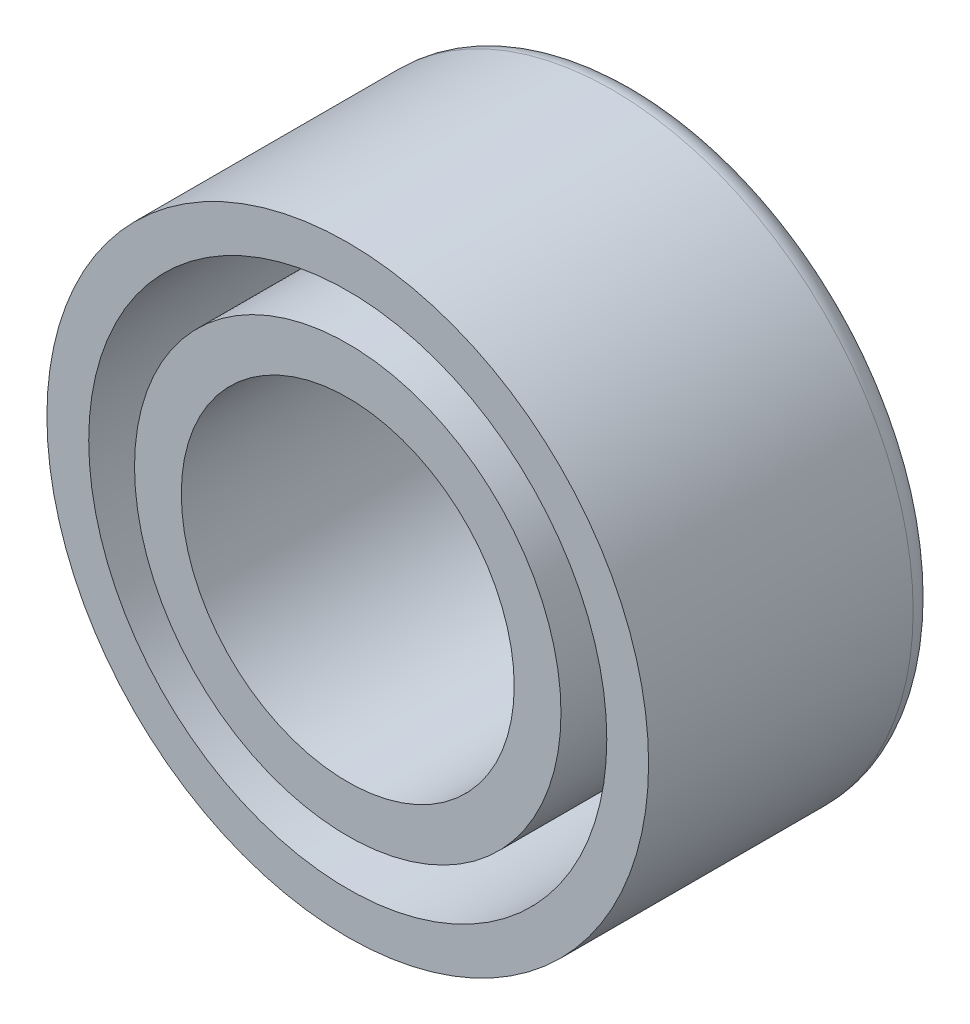
from build123d import *

# Parameters (mm, degrees)
SKETCH1_R           = 12.5095
SKETCH1_R_2         = 6.9215
BOSS_EXTRUDE1_DEPTH = 12
FILLET1_R           = 1
SKETCH2_R           = 10.7715
SKETCH2_R_2         = 8.8665
CUT_EXTRUDE1_DEPTH  = 9


with BuildPart() as part:
    # Sketch1 → Boss-Extrude1 (new body)
    with BuildSketch(Plane.XY):
        Circle(SKETCH1_R)
        Circle(SKETCH1_R_2, mode=Mode.SUBTRACT)
    extrude(amount=BOSS_EXTRUDE1_DEPTH)

    # Fillet1
    fillet1_edges = [part.edges().sort_by_distance(p)[0] for p in [
        (-12.5095, 0, 0),
        (-6.9215, 0, 0),
    ]]
    fillet(fillet1_edges, radius=FILLET1_R)

    # Sketch2 → Cut-Extrude1 (cut)
    with BuildSketch(Plane.XY.offset(12)):
        Circle(SKETCH2_R)
        Circle(SKETCH2_R_2, mode=Mode.SUBTRACT)
    extrude(amount=-CUT_EXTRUDE1_DEPTH, mode=Mode.SUBTRACT)


solid = part.part
